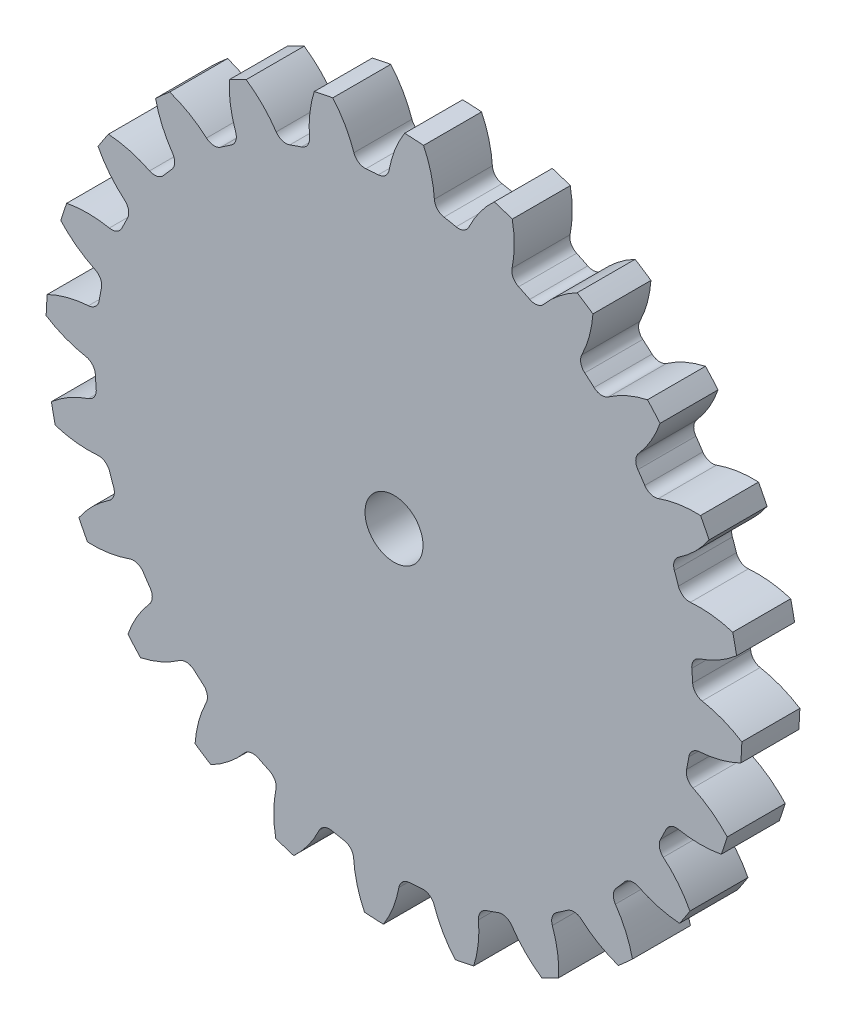
from build123d import *

# Parameters (mm, degrees)
CROQUIS1_R              = 30
SALIENTE_EXTRUIR1_DEPTH = 2.5
CORTAR_EXTRUIR1_DEPTH   = 6
MATRIZC1_COUNT          = 24
CROQUIS3_R              = 2.5
CORTAR_EXTRUIR2_DEPTH   = 6


with BuildPart() as part:
    # Croquis1 → Saliente-Extruir1 (new body, symmetric)
    with BuildSketch(Plane.XY):
        Circle(CROQUIS1_R)
    extrude(amount=SALIENTE_EXTRUIR1_DEPTH, both=True)

    # Croquis2 → Cortar-Extruir1 (cut, through all)
    with BuildSketch(Plane.XY.offset(2.5)):
        with BuildLine():
            ThreePointArc((0.915279649, 29.986034469), (-2.193162151, 29.919726599), (-5.278047422, 29.532054033))
            ThreePointArc((-5.278047422, 29.532054033), (-4.213051861, 28.025623064), (-3.455227209, 26.343585131))
            ThreePointArc((-3.455227209, 26.343585131), (-3.052028362, 25.825773823), (-2.414647226, 25.669430775))
            ThreePointArc((-2.414647226, 25.669430775), (-1.884858381, 25.713761033), (-1.354268124, 25.747158201))
            ThreePointArc((-1.354268124, 25.747158201), (-0.746497706, 25.99477278), (-0.4231156, 26.565843593))
            ThreePointArc((-0.4231156, 26.565843593), (0.081334748, 28.340408232), (0.915279649, 29.986034469))
        make_face()
    cortar_extruir1 = extrude(amount=-CORTAR_EXTRUIR1_DEPTH, mode=Mode.SUBTRACT)

    # MatrizC1: Cortar-Extruir1 ×24 about axis
    matrizc1_axis = Axis((0, 0, 0), (0, 0, 1))
    for i in range(1, MATRIZC1_COUNT):
        add(cortar_extruir1.rotate(matrizc1_axis, i * 360 / MATRIZC1_COUNT), mode=Mode.SUBTRACT)

    # Croquis3 → Cortar-Extruir2 (cut, through all)
    with BuildSketch(Plane.XY.offset(2.5)):
        Circle(CROQUIS3_R)
    extrude(amount=-CORTAR_EXTRUIR2_DEPTH, mode=Mode.SUBTRACT)


solid = part.part
